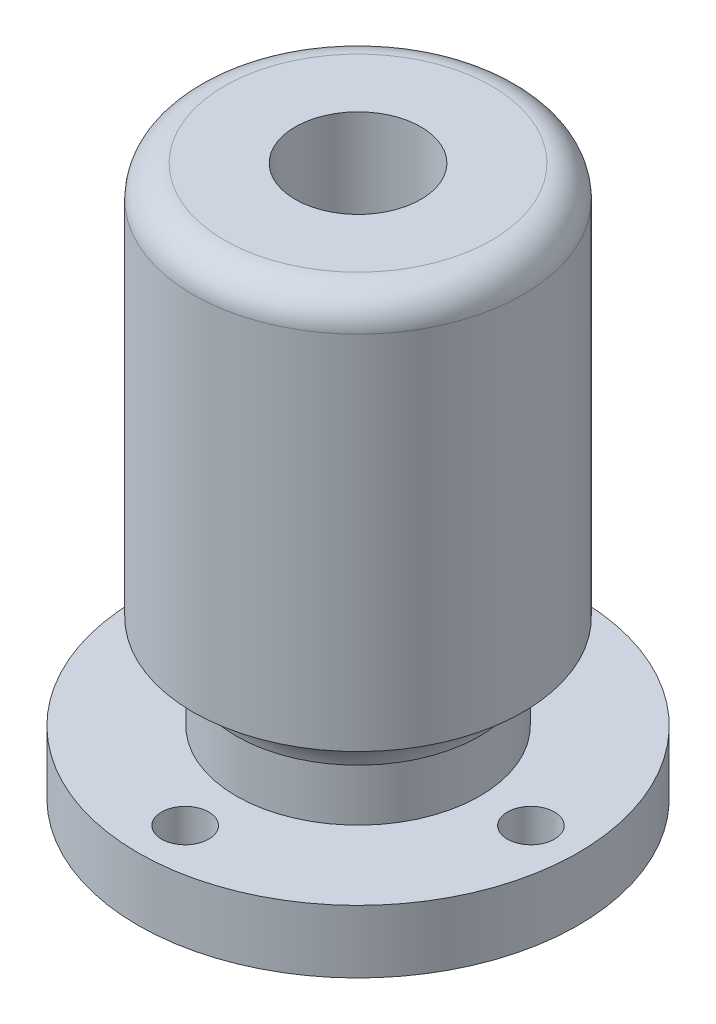
from build123d import *

# Parameters (mm, degrees)
SKETCH1_R           = 14
SKETCH1_R_2         = 1.5
SKETCH1_R_3         = 4.25
BOSS_EXTRUDE1_DEPTH = 4
SKETCH2_R           = 7.75
SKETCH2_R_2         = 4.25
BOSS_EXTRUDE2_DEPTH = 6
SKETCH3_R           = 10.5
SKETCH3_R_2         = 4
BOSS_EXTRUDE3_DEPTH = 25
FILLET1_R           = 2


with BuildPart() as part:
    # Sketch1 → Boss-Extrude1 (new body)
    with BuildSketch(Plane(origin=(0, 0, 0), x_dir=(1, 0, 0), z_dir=(0, 1, 0))):
        Circle(SKETCH1_R)
        with Locations((0, 11)):
            Circle(SKETCH1_R_2, mode=Mode.SUBTRACT)
        with Locations((0, -11)):
            Circle(SKETCH1_R_2, mode=Mode.SUBTRACT)
        with Locations((11, 0)):
            Circle(SKETCH1_R_2, mode=Mode.SUBTRACT)
        with Locations((-11, 0)):
            Circle(SKETCH1_R_2, mode=Mode.SUBTRACT)
        Circle(SKETCH1_R_3, mode=Mode.SUBTRACT)
    extrude(amount=BOSS_EXTRUDE1_DEPTH)

    # Sketch2 → Boss-Extrude2 (add)
    with BuildSketch(Plane(origin=(0, 4, 0), x_dir=(1, 0, 0), z_dir=(0, 1, 0))):
        Circle(SKETCH2_R)
        Circle(SKETCH2_R_2, mode=Mode.SUBTRACT)
    extrude(amount=BOSS_EXTRUDE2_DEPTH)



with BuildPart() as body_2:
    # Sketch3 → Boss-Extrude3 (new body)
    with BuildSketch(Plane(origin=(0, 10, 0), x_dir=(1, 0, 0), z_dir=(0, 1, 0))):
        Circle(SKETCH3_R)
        Circle(SKETCH3_R_2, mode=Mode.SUBTRACT)
    extrude(amount=BOSS_EXTRUDE3_DEPTH)


with BuildPart() as part_1:
    add(part.part)

    add(body_2.part)  # Revolve1 merges body 2
    # Sketch4 → Revolve1 (revolve)
    with BuildSketch(Plane(origin=(0, 0, 0), x_dir=(0, 0, -1), z_dir=(1, 0, 0))):
        with BuildLine():
            Line((7.75, 10), (10.5, 10))
            add(Edge.make_bspline(
                [(10.5, 10), (8.289227016, 9.506903226), (7.75, 7.304459311)],
                knots=[0, 0, 0, 1, 1, 1], degree=2))
            Line((7.75, 7.304459311), (7.75, 10))
        make_face()
    revolve(axis=Axis((0, 36.75, 0), (0, -1, 0)))

    # Fillet1
    fillet1_edges = [part_1.edges().sort_by_distance(p)[0] for p in [
        (-10.5, 35, 0),
    ]]
    fillet(fillet1_edges, radius=FILLET1_R)


solid = part_1.part
